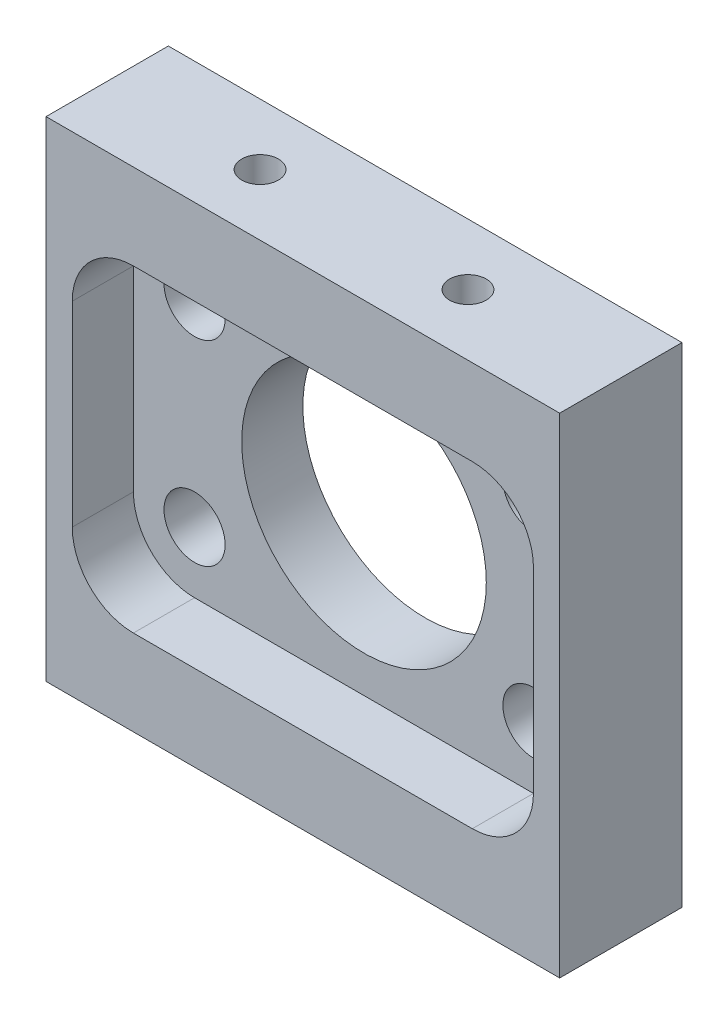
from build123d import *

# Parameters (mm, degrees)
SKIZZE1_W                       = 21
SKIZZE1_H                       = 20
SKIZZE1_R                       = 5
SKIZZE1_R_2                     = 1.25
AUFSATZ_LINEAR_AUSTRAGEN1_DEPTH = 2.5
SCHNITT_LINEAR_START            = 2.5
SCHNITT_LINEAR_AUSTRAGEN1_DEPTH = 2.5
SKIZZE4_R                       = 0.75
SCHNITT_LINEAR_AUSTRAGEN2_DEPTH = 3


with BuildPart() as part:
    # Skizze1 → Aufsatz-Linear austragen1 (new body, symmetric)
    with BuildSketch(Plane.XY):
        Rectangle(SKIZZE1_W, SKIZZE1_H)
        Circle(SKIZZE1_R, mode=Mode.SUBTRACT)
        with Locations((6.92820323, 4)):
            Circle(SKIZZE1_R_2, mode=Mode.SUBTRACT)
        with Locations((-6.92820323, -4)):
            Circle(SKIZZE1_R_2, mode=Mode.SUBTRACT)
        with Locations((-6.92820323, 4)):
            Circle(SKIZZE1_R_2, mode=Mode.SUBTRACT)
        with Locations((6.92820323, -4)):
            Circle(SKIZZE1_R_2, mode=Mode.SUBTRACT)
    extrude(amount=AUFSATZ_LINEAR_AUSTRAGEN1_DEPTH, both=True)

    # Skizze1_3 → Schnitt-Linear austragen1 (cut)
    with BuildSketch(Plane.XY.offset(SCHNITT_LINEAR_START)):
        with BuildLine():
            Line((-6.92820323, 6.5), (6.92820323, 6.5))
            ThreePointArc((6.92820323, 6.5), (8.695970183, 5.767766953), (9.42820323, 4))
            Line((9.42820323, 4), (9.42820323, -4))
            ThreePointArc((9.42820323, -4), (8.695970183, -5.767766953), (6.92820323, -6.5))
            Line((6.92820323, -6.5), (-6.92820323, -6.5))
            ThreePointArc((-6.92820323, -6.5), (-8.695970183, -5.767766953), (-9.42820323, -4))
            Line((-9.42820323, -4), (-9.42820323, 4))
            ThreePointArc((-9.42820323, 4), (-8.695970183, 5.767766953), (-6.92820323, 6.5))
        make_face()
    extrude(amount=-SCHNITT_LINEAR_AUSTRAGEN1_DEPTH, mode=Mode.SUBTRACT)

    # Skizze4 → Schnitt-Linear austragen2 (cut)
    with BuildSketch(Plane(origin=(0, 10, 0), x_dir=(1, 0, 0), z_dir=(0, 1, 0))):
        with Locations((-4.25, 0)):
            Circle(SKIZZE4_R)
        with Locations((4.25, 0)):
            Circle(SKIZZE4_R)
    schnitt_linear_austragen2 = extrude(amount=-SCHNITT_LINEAR_AUSTRAGEN2_DEPTH, mode=Mode.SUBTRACT)

    # Spiegeln1: Schnitt-Linear austragen2 across plane
    add(schnitt_linear_austragen2.mirror(Plane.ZX), mode=Mode.SUBTRACT)


solid = part.part
